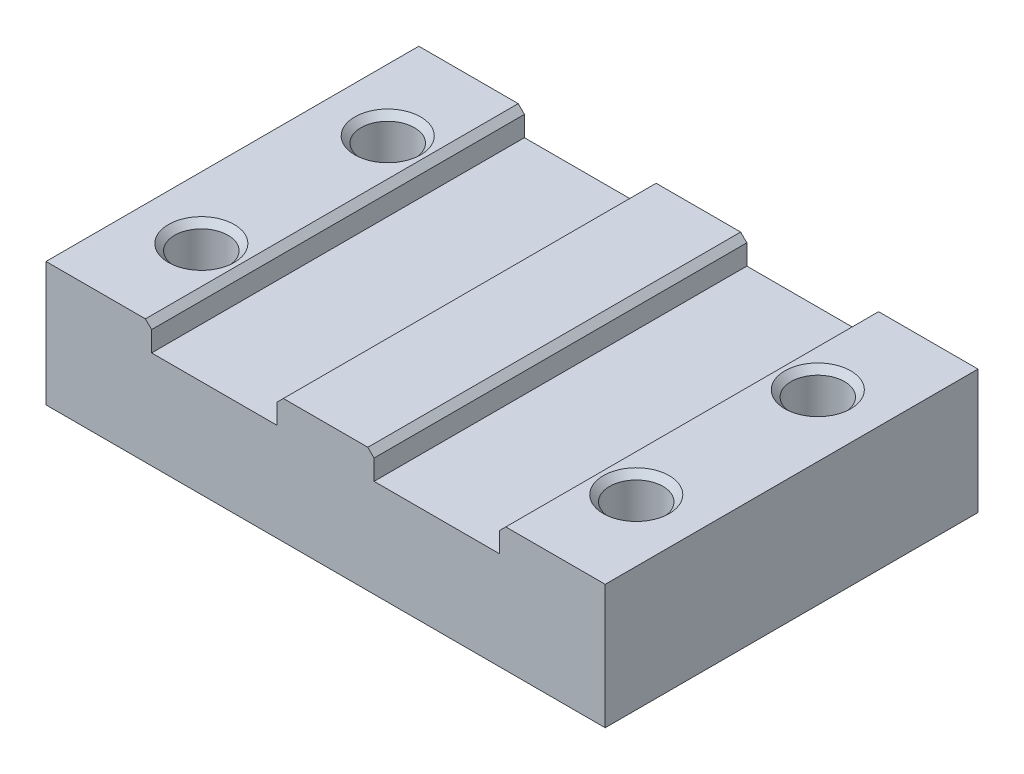
from build123d import *

# Parameters (mm, degrees)
SKETCH1_W           = 90
SKETCH1_H           = 60
BOSS_EXTRUDE1_DEPTH = 20
CUT_EXTRUDE1_DEPTH  = 61
SKETCH3_R           = 4.3
CUT_EXTRUDE2_DEPTH  = 21
CHAMFER1_SIZE       = 1
CHAMFER2_SIZE       = 1


with BuildPart() as part:
    # Sketch1 → Boss-Extrude1 (new body)
    with BuildSketch(Plane(origin=(0, 0, 0), x_dir=(1, 0, 0), z_dir=(0, 1, 0))):
        Rectangle(SKETCH1_W, SKETCH1_H)
    extrude(amount=BOSS_EXTRUDE1_DEPTH)

    # Sketch2 → Cut-Extrude1 (cut, through all)
    with BuildSketch(Plane.XY.offset(30)):
        Polygon((28, 24.25), (-28, 24.25), (-28, 15.75), (-7.8, 15.75), (-7.8, 20), (7.8, 20), (7.8, 15.75), (28, 15.75), align=None)
    extrude(amount=-CUT_EXTRUDE1_DEPTH, mode=Mode.SUBTRACT)

    # Sketch3 → Cut-Extrude2 (cut, through all)
    with BuildSketch(Plane.XZ):
        with Locations((-35, 15)):
            Circle(SKETCH3_R)
        with Locations((-35, -15)):
            Circle(SKETCH3_R)
        with Locations((35, -14.217273236)):
            Circle(SKETCH3_R)
        with Locations((35, 15)):
            Circle(SKETCH3_R)
    extrude(amount=-CUT_EXTRUDE2_DEPTH, mode=Mode.SUBTRACT)

    # Chamfer1
    chamfer1_edges = [part.edges().sort_by_distance(p)[0] for p in [
        (28, 20, 0),
        (-28, 20, 0),
        (7.8, 20, 0),
        (-7.8, 20, 0),
    ]]
    chamfer(chamfer1_edges, length=CHAMFER1_SIZE)

    # Chamfer2
    chamfer2_edges = [part.edges().sort_by_distance(p)[0] for p in [
        (-39.3, 20, 15),
        (-39.3, 20, -15),
        (30.7, 20, -14.217273236),
        (30.7, 20, 15),
    ]]
    chamfer(chamfer2_edges, length=CHAMFER2_SIZE)


solid = part.part
